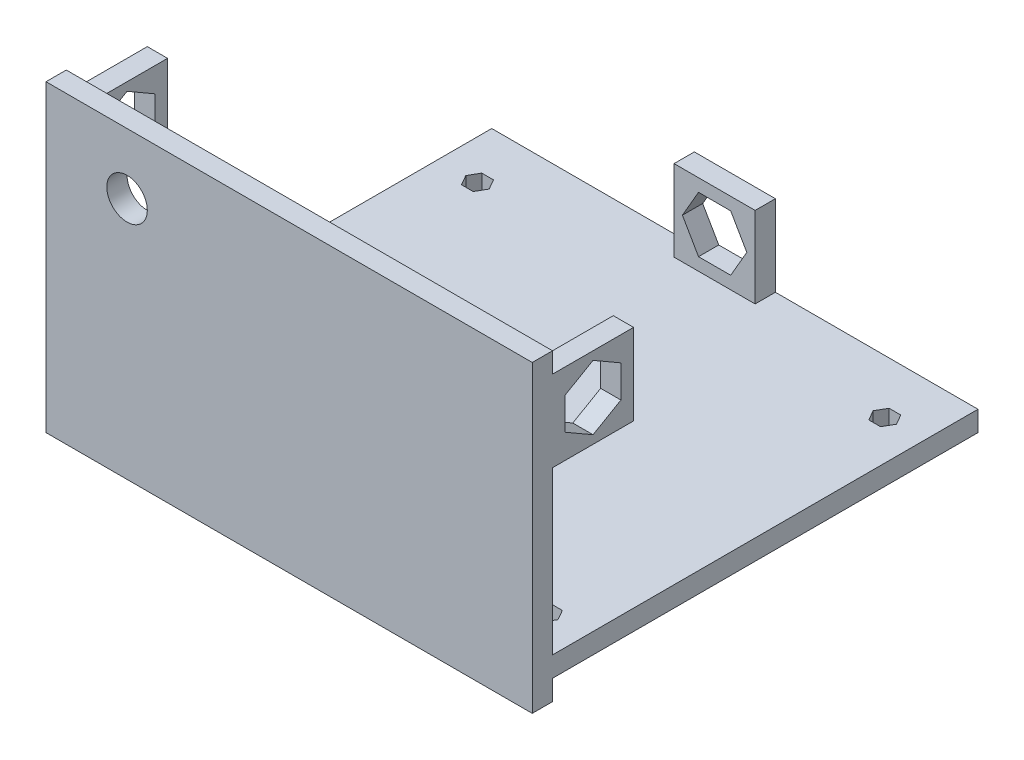
from build123d import *

# Parameters (mm, degrees)
SKETCH1_W               = 76.2
SKETCH1_H               = 47.625
BOSS_EXTRUDE1_DEPTH     = 3.175
SKETCH2_W               = 76.2
SKETCH2_H               = 3.175
BOSS_EXTRUDE2_DEPTH     = 66.675
SKETCH6_W               = 12.7
SKETCH6_H               = 12.7
BOSS_EXTRUDE4_DEPTH     = 3.175
SKETCH7_W               = 12.7
SKETCH7_H               = 12.7
BOSS_EXTRUDE5_DEPTH     = 3.175
SKETCH8_W               = 12.7
SKETCH8_H               = 12.7
BOSS_EXTRUDE6_DEPTH     = 3.175
CUT_EXTRUDE4_DEPTH      = 3.175
CUT_EXTRUDE5_DEPTH      = 1
CUT_EXTRUDE5_DEPTH_BACK = 77.2
SKETCH11_R              = 3.175
CUT_EXTRUDE6_DEPTH      = 3.175
CUT_EXTRUDE7_DEPTH      = 3.175


with BuildPart() as part:
    # Sketch1 → Boss-Extrude1 (new body)
    with BuildSketch(Plane.XY):
        Rectangle(SKETCH1_W, SKETCH1_H)
    extrude(amount=BOSS_EXTRUDE1_DEPTH)

    # Sketch2 → Boss-Extrude2 (add)
    with BuildSketch(Plane(origin=(0, 0, 0), x_dir=(-1, 0, 0), z_dir=(0, 0, -1))):
        with Locations((0, -19.05)):
            Rectangle(SKETCH2_W, SKETCH2_H)
    extrude(amount=BOSS_EXTRUDE2_DEPTH)

    # Sketch6 → Boss-Extrude4 (add)
    with BuildSketch(Plane(origin=(38.1, 0, 0), x_dir=(0, 0, -1), z_dir=(1, 0, 0))):
        with Locations((6.35, 14.2875)):
            Rectangle(SKETCH6_W, SKETCH6_H)
    extrude(amount=-BOSS_EXTRUDE4_DEPTH)

    # Sketch7 → Boss-Extrude5 (add)
    with BuildSketch(Plane.ZY.offset(38.1)):
        with Locations((-6.35, 14.2875)):
            Rectangle(SKETCH7_W, SKETCH7_H)
    extrude(amount=-BOSS_EXTRUDE5_DEPTH)

    # Sketch8 → Boss-Extrude6 (add)
    with BuildSketch(Plane(origin=(0, 0, -66.675), x_dir=(-1, 0, 0), z_dir=(0, 0, -1))):
        with Locations((0, -11.1125)):
            Rectangle(SKETCH8_W, SKETCH8_H)
    extrude(amount=-BOSS_EXTRUDE6_DEPTH)

    # Sketch9 → Cut-Extrude4 (cut)
    with BuildSketch(Plane(origin=(0, 0, -66.675), x_dir=(-1, 0, 0), z_dir=(0, 0, -1))):
        Polygon((2.522327856, -6.7437), (-2.522327856, -6.7437), (-5.044655712, -11.1125), (-2.522327856, -15.4813), (2.522327856, -15.4813), (5.044655712, -11.1125), align=None)
    extrude(amount=-CUT_EXTRUDE4_DEPTH, mode=Mode.SUBTRACT)

    # Sketch10 → Cut-Extrude5 (cut, two sides)
    with BuildSketch(Plane(origin=(38.1, 0, 0), x_dir=(0, 0, -1), z_dir=(1, 0, 0))) as cut_extrude5_sk:
        Polygon((10.7188, 11.765172144), (10.7188, 16.809827856), (6.35, 19.332155712), (1.9812, 16.809827856), (1.9812, 11.765172144), (6.35, 9.242844288), align=None)
    extrude(amount=CUT_EXTRUDE5_DEPTH, mode=Mode.SUBTRACT)
    extrude(cut_extrude5_sk.sketch, amount=-CUT_EXTRUDE5_DEPTH_BACK, mode=Mode.SUBTRACT)

    # Sketch11 → Cut-Extrude6 (cut)
    with BuildSketch(Plane.XY.offset(3.175)):
        with Locations((-25.4, 14.2875)):
            Circle(SKETCH11_R)
    extrude(amount=-CUT_EXTRUDE6_DEPTH, mode=Mode.SUBTRACT)

    # Sketch12 → Cut-Extrude7 (cut)
    with BuildSketch(Plane(origin=(0, -17.4625, 0), x_dir=(1, 0, 0), z_dir=(0, 1, 0))):
        Polygon((-8.983187105, 5.5499), (-8.066643552, 3.9624), (-6.233556448, 3.9624), (-5.317012895, 5.5499), (-6.233556448, 7.1374), (-8.066643552, 7.1374), align=None)
        Polygon((32.831643552, 3.6322), (33.748187105, 5.2197), (32.831643552, 6.8072), (30.998556448, 6.8072), (30.082012895, 5.2197), (30.998556448, 3.6322), align=None)
        Polygon((33.748187105, 58.2549), (32.831643552, 59.8424), (30.998556448, 59.8424), (30.082012895, 58.2549), (30.998556448, 56.6674), (32.831643552, 56.6674), align=None)
        Polygon((-30.998556448, 29.3624), (-32.831643552, 29.3624), (-33.748187105, 27.7749), (-32.831643552, 26.1874), (-30.998556448, 26.1874), (-30.082012895, 27.7749), align=None)
        Polygon((-30.082012895, 58.2549), (-30.998556448, 59.8424), (-32.831643552, 59.8424), (-33.748187105, 58.2549), (-32.831643552, 56.6674), (-30.998556448, 56.6674), align=None)
    extrude(amount=-CUT_EXTRUDE7_DEPTH, mode=Mode.SUBTRACT)


solid = part.part
